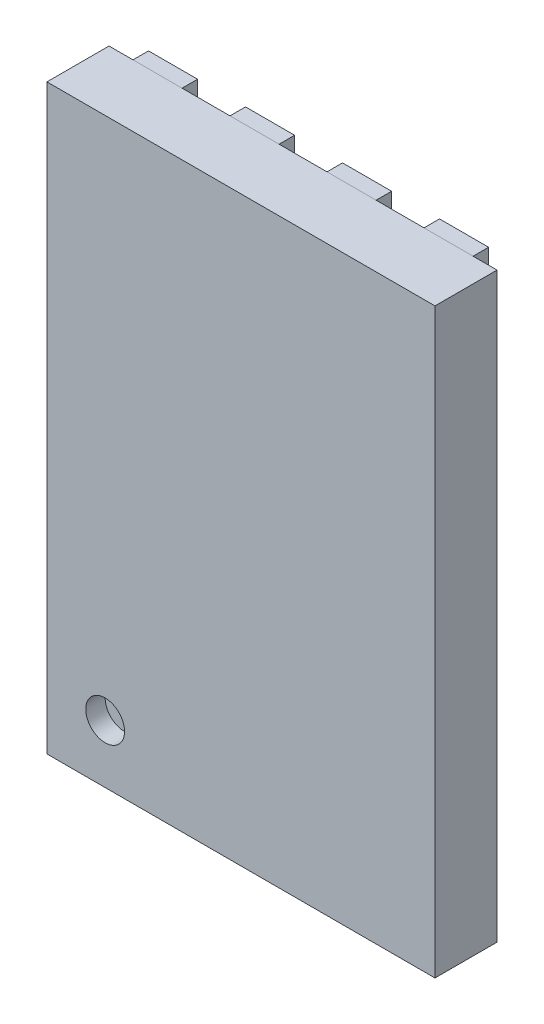
from build123d import *

# Parameters (mm, degrees)
SKETCH1_W             = 2
SKETCH1_H             = 3
BOSS_EXTRUDE1_DEPTH   = 0.32
SKETCH2_R             = 0.1
CUT_EXTRUDE1_DEPTH    = 0.1
BOSS_EXTRUDE2_DEPTH   = 0.08
SKETCH3_W             = 0.253
SKETCH3_H             = 0.4
BOSS_EXTRUDE2_2_DEPTH = 0.08
BOSS_EXTRUDE2_3_DEPTH = 0.08
BOSS_EXTRUDE2_4_DEPTH = 0.08
BOSS_EXTRUDE2_5_DEPTH = 0.08
BOSS_EXTRUDE2_6_DEPTH = 0.08
BOSS_EXTRUDE2_7_DEPTH = 0.08
BOSS_EXTRUDE2_8_DEPTH = 0.08
BOSS_EXTRUDE2_9_DEPTH = 0.08


with BuildPart() as part:
    # Sketch1 → Boss-Extrude1 (new body)
    with BuildSketch(Plane.XY):
        with Locations((1, 1.5)):
            Rectangle(SKETCH1_W, SKETCH1_H)
    extrude(amount=BOSS_EXTRUDE1_DEPTH)

    # Sketch2 → Cut-Extrude1 (cut)
    with BuildSketch(Plane.XY.offset(0.32)):
        with Locations((0.3, 0.3)):
            Circle(SKETCH2_R)
    extrude(amount=-CUT_EXTRUDE1_DEPTH, mode=Mode.SUBTRACT)


with BuildPart() as body_2:
    # Sketch3 → Boss-Extrude2 (new body)
    with BuildSketch(Plane(origin=(0, 0, 0), x_dir=(-1, 0, 0), z_dir=(0, 0, -1))):
        Polygon((-0.538553391, 0.625), (-0.185, 0.978553391), (-0.185, 2.375), (-1.815, 2.375), (-1.815, 0.625), align=None)
    extrude(amount=BOSS_EXTRUDE2_DEPTH)


with BuildPart() as body_3:
    # Sketch3 → Boss-Extrude2 2 (new body)
    with BuildSketch(Plane(origin=(0, 0, 0), x_dir=(-1, 0, 0), z_dir=(0, 0, -1))):
        with Locations((-1.75, 2.8)):
            Rectangle(SKETCH3_W, SKETCH3_H)
    extrude(amount=BOSS_EXTRUDE2_2_DEPTH)


with BuildPart() as body_4:
    # Sketch3 → Boss-Extrude2 3 (new body)
    with BuildSketch(Plane(origin=(0, 0, 0), x_dir=(-1, 0, 0), z_dir=(0, 0, -1))):
        with Locations((-1.25, 2.8)):
            Rectangle(SKETCH3_W, SKETCH3_H)
    extrude(amount=BOSS_EXTRUDE2_3_DEPTH)


with BuildPart() as body_5:
    # Sketch3 → Boss-Extrude2 4 (new body)
    with BuildSketch(Plane(origin=(0, 0, 0), x_dir=(-1, 0, 0), z_dir=(0, 0, -1))):
        with Locations((-0.75, 2.8)):
            Rectangle(SKETCH3_W, SKETCH3_H)
    extrude(amount=BOSS_EXTRUDE2_4_DEPTH)


with BuildPart() as body_6:
    # Sketch3 → Boss-Extrude2 5 (new body)
    with BuildSketch(Plane(origin=(0, 0, 0), x_dir=(-1, 0, 0), z_dir=(0, 0, -1))):
        with Locations((-0.25, 2.8)):
            Rectangle(SKETCH3_W, SKETCH3_H)
    extrude(amount=BOSS_EXTRUDE2_5_DEPTH)


with BuildPart() as body_7:
    # Sketch3 → Boss-Extrude2 6 (new body)
    with BuildSketch(Plane(origin=(0, 0, 0), x_dir=(-1, 0, 0), z_dir=(0, 0, -1))):
        with Locations((-1.25, 0.2)):
            Rectangle(SKETCH3_W, SKETCH3_H)
    extrude(amount=BOSS_EXTRUDE2_6_DEPTH)


with BuildPart() as body_8:
    # Sketch3 → Boss-Extrude2 7 (new body)
    with BuildSketch(Plane(origin=(0, 0, 0), x_dir=(-1, 0, 0), z_dir=(0, 0, -1))):
        with Locations((-0.75, 0.2)):
            Rectangle(SKETCH3_W, SKETCH3_H)
    extrude(amount=BOSS_EXTRUDE2_7_DEPTH)


with BuildPart() as body_9:
    # Sketch3 → Boss-Extrude2 8 (new body)
    with BuildSketch(Plane(origin=(0, 0, 0), x_dir=(-1, 0, 0), z_dir=(0, 0, -1))):
        with Locations((-0.25, 0.2)):
            Rectangle(SKETCH3_W, SKETCH3_H)
    extrude(amount=BOSS_EXTRUDE2_8_DEPTH)


with BuildPart() as body_10:
    # Sketch3 → Boss-Extrude2 9 (new body)
    with BuildSketch(Plane(origin=(0, 0, 0), x_dir=(-1, 0, 0), z_dir=(0, 0, -1))):
        with Locations((-1.75, 0.2)):
            Rectangle(SKETCH3_W, SKETCH3_H)
    extrude(amount=BOSS_EXTRUDE2_9_DEPTH)


solid = Compound([part.part, body_2.part, body_3.part, body_4.part, body_5.part, body_6.part, body_7.part, body_8.part, body_9.part, body_10.part])
